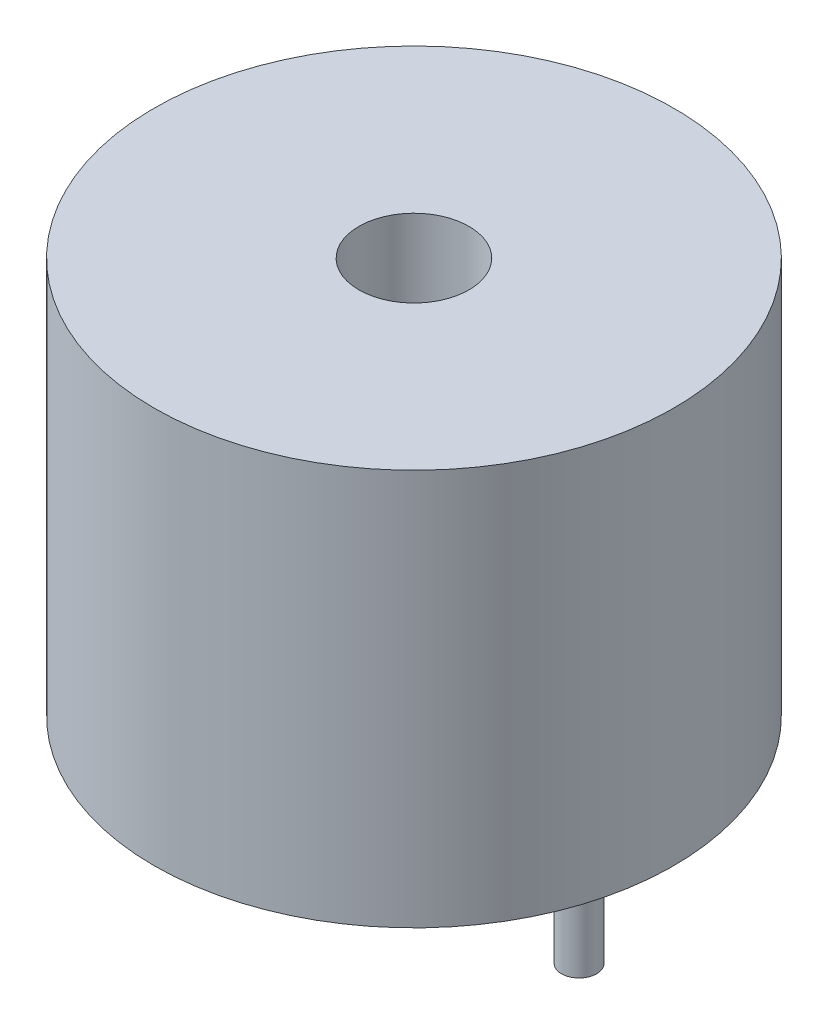
from build123d import *

# Parameters (mm, degrees)
ESQUISSE1_R             = 5.9
BOSS_EXTRU_1_DEPTH      = 9
ESQUISSE2_R             = 1.25
ENL_V_MAT_EXTRU_1_DEPTH = 3
ESQUISSE3_R             = 0.4
BOSS_EXTRU_2_DEPTH      = 3


with BuildPart() as part:
    # Esquisse1 → Boss.-Extru.1 (new body)
    with BuildSketch(Plane(origin=(0, 0, 0), x_dir=(1, 0, 0), z_dir=(0, 1, 0))):
        Circle(ESQUISSE1_R)
    extrude(amount=BOSS_EXTRU_1_DEPTH)

    # Esquisse2 → Enlèv. mat.-Extru.1 (cut)
    with BuildSketch(Plane(origin=(0, 9, 0), x_dir=(1, 0, 0), z_dir=(0, 1, 0))):
        Circle(ESQUISSE2_R)
    extrude(amount=-ENL_V_MAT_EXTRU_1_DEPTH, mode=Mode.SUBTRACT)

    # Esquisse3 → Boss.-Extru.2 (add)
    with BuildSketch(Plane.XZ):
        with Locations((3.75, 0)):
            Circle(ESQUISSE3_R)
        with Locations((-3.75, 0)):
            Circle(ESQUISSE3_R)
    extrude(amount=BOSS_EXTRU_2_DEPTH)


solid = part.part
